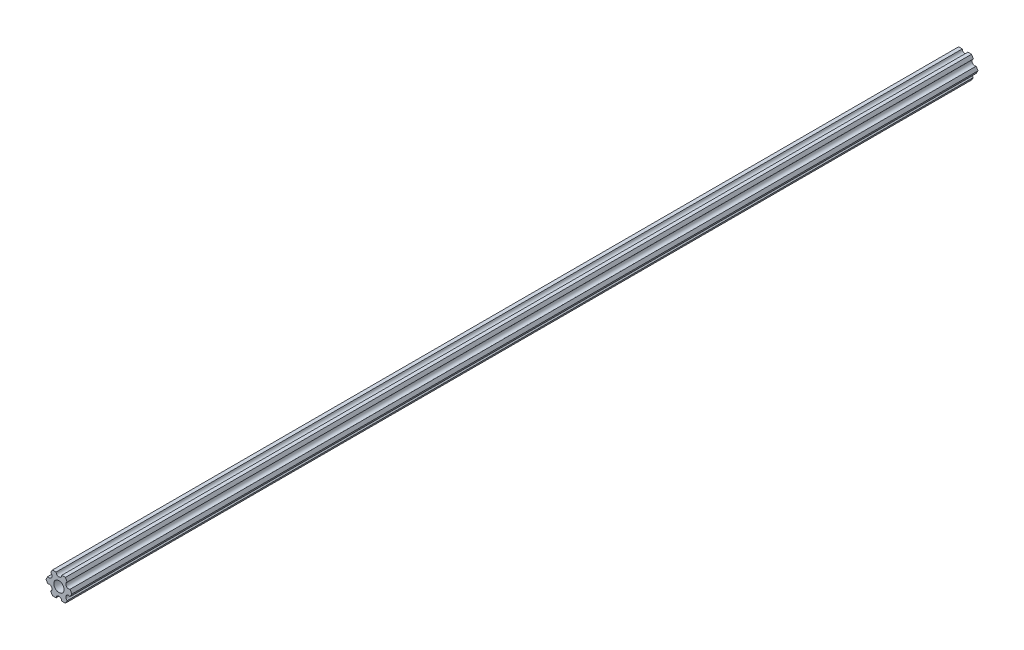
from build123d import *

# Parameters (mm, degrees)
SKETCH1_R           = 2.9337
BOSS_EXTRUDE1_DEPTH = 514.35


with BuildPart() as part:
    # Sketch1 → Boss-Extrude1 (new body)
    with BuildSketch(Plane.XY):
        with BuildLine():
            Line((-1.587500385, 6.349999904), (-3.666174594, 6.349999778))
            Line((-3.666174594, 6.349999778), (-4.70551159, 4.549815043))
            ThreePointArc((-4.70551159, 4.549815043), (-4.12444613, 2.38124975), (-6.293011423, 1.80018429))
            Line((-6.293011423, 1.80018429), (-7.332348419, -4.44e-07))
            Line((-7.332348419, -4.44e-07), (-6.293011205, -1.800185053))
            ThreePointArc((-6.293011205, -1.800185053), (-4.124445841, -2.38125025), (-4.705511038, -4.549815614))
            Line((-4.705511038, -4.549815614), (-3.666173825, -6.350000222))
            Line((-3.666173825, -6.350000222), (-1.587499615, -6.350000096))
            ThreePointArc((-1.587499615, -6.350000096), (2.89e-07, -4.7625), (1.587500385, -6.349999904))
            Line((1.587500385, -6.349999904), (3.666174594, -6.349999778))
            Line((3.666174594, -6.349999778), (4.70551159, -4.549815043))
            ThreePointArc((4.70551159, -4.549815043), (4.12444613, -2.38124975), (6.293011423, -1.80018429))
            Line((6.293011423, -1.80018429), (7.332348419, 4.44e-07))
            Line((7.332348419, 4.44e-07), (6.293011205, 1.800185053))
            ThreePointArc((6.293011205, 1.800185053), (4.124445841, 2.38125025), (4.705511038, 4.549815614))
            Line((4.705511038, 4.549815614), (3.666173825, 6.350000222))
            Line((3.666173825, 6.350000222), (1.587499615, 6.350000096))
            ThreePointArc((1.587499615, 6.350000096), (-2.89e-07, 4.7625), (-1.587500385, 6.349999904))
        make_face()
        Circle(SKETCH1_R, mode=Mode.SUBTRACT)
    extrude(amount=BOSS_EXTRUDE1_DEPTH)


solid = part.part
